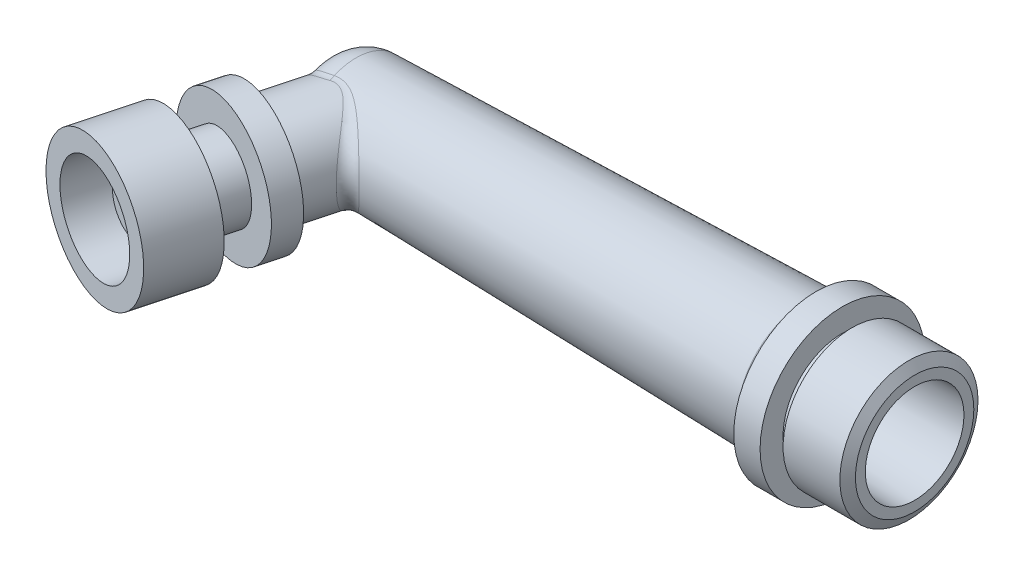
from build123d import *

# Parameters (mm, degrees)
BOSS_EXTRUDE1_REACH = 106.633
SKETCH3_R           = 7.5
CUT_EXTRUDE1_REACH  = 110.833
SKETCH4_R           = 2.5
FILLET1_R           = 2


with BuildPart() as part:
    # Sketch1 → Revolve1 (revolve)
    with BuildSketch(Plane(origin=(0, 0, 0), x_dir=(1, 0, 0), z_dir=(0, 1, 0))):
        with BuildLine():
            Line((-83, 5.5), (0, 7.5))
            Line((0, 7.5), (0, 9))
            Line((0, 9), (-0.866025404, 10.5))
            Line((-0.866025404, 10.5), (-9.5, 10.5))
            Line((-9.5, 10.5), (-9.5, 9))
            Line((-9.5, 9), (-11, 9))
            Line((-11, 9), (-11, 12.5))
            Line((-11, 12.5), (-15, 12.5))
            Line((-15, 12.5), (-15, 11.95238778))
            ThreePointArc((-15, 11.95238778), (-15.568854031, 10.555311829), (-16.951821214, 9.952968164))
            Line((-16.951821214, 9.952968164), (-84.920460151, 8.315169635))
            ThreePointArc((-84.920460151, 8.315169635), (-88.373865073, 6.813416653), (-89.8, 3.328103648))
            Line((-89.8, 3.328103648), (-89.8, 0))
            Line((-89.8, 0), (-88.5, 0))
            ThreePointArc((-88.5, 0), (-86.889087297, 3.889087297), (-83, 5.5))
        make_face()
    revolve(axis=Axis((0, 0, 0), (-1, 0, 0)))

    # Sketch3 → Boss-Extrude1 (add, up to next)
    with BuildSketch(Plane(origin=(-9.183412374, 0, 34.272961568), x_dir=(-0.9659258262890701, 0, -0.258819045102514), z_dir=(0.258819045102514, 0, -0.9659258262890702)), mode=Mode.PRIVATE) as boss_extrude1_sk1:
        with Locations(Location((80.171843582, 0, 0), (0, 0, 83.1298318))):
            Circle(SKETCH3_R)
    boss_extrude1_tool1 = extrude(boss_extrude1_sk1.sketch, amount=BOSS_EXTRUDE1_REACH, mode=Mode.PRIVATE) - part.part


with BuildPart() as body_2:
    # Sketch2 → Revolve2 (revolve)
    with BuildSketch(Plane(origin=(0, 0, 0), x_dir=(1, 0, 0), z_dir=(0, 1, 0))):
        Polygon((-90.635161831, -28.494811876), (-86.623466631, -13.522961568), (-93.867910329, -11.58181873), (-96.524206351, -10.870066356), (-97.559482531, -14.733769661), (-93.45429777, -15.833750603), (-95.00721204, -21.62930556), (-99.353878258, -20.464619857), (-101.94206871, -30.12387812), (-99.044291231, -30.900335256), (-97.103148392, -23.655891558), (-93.722408, -24.561758216), (-94.498865136, -27.459535695), align=None)
    revolve(axis=Axis((-78.735902289, 0, -15.913829307), (-0.25881904510251397, 0, 0.9659258262890702)))


with BuildPart() as part_1:
    add(part.part)

    add(body_2.part)  # Boss-Extrude1 merges body 2
    add(boss_extrude1_tool1.solids().sort_by_distance((-86.623467, 0, 13.522962))[0])

    # Sketch4 → Cut-Extrude1 (cut, up to next)
    with BuildSketch(Plane(origin=(-13.195107573, 0, 49.244811876), x_dir=(0.9659258262890701, 0, 0.258819045102514), z_dir=(-0.258819045102514, 0, 0.9659258262890702)), mode=Mode.PRIVATE) as cut_extrude1_sk1:
        with Locations((-80.171843582, 0)):
            Circle(SKETCH4_R)
    cut_extrude1_tool1 = extrude(cut_extrude1_sk1.sketch, amount=-CUT_EXTRUDE1_REACH, mode=Mode.PRIVATE) & part_1.part
    add(cut_extrude1_tool1.solids().sort_by_distance((-90.635162, 0, 28.494812))[0], mode=Mode.SUBTRACT)

    # Fillet1
    fillet1_edges = [part_1.edges().sort_by_distance(p)[0] for p in [
        (-77.511309609, -1e-09, 8.493703383),
        (-88.787055838, -5.699618584, 2.762538857),
    ]]
    fillet(fillet1_edges, radius=FILLET1_R)


solid = part_1.part
